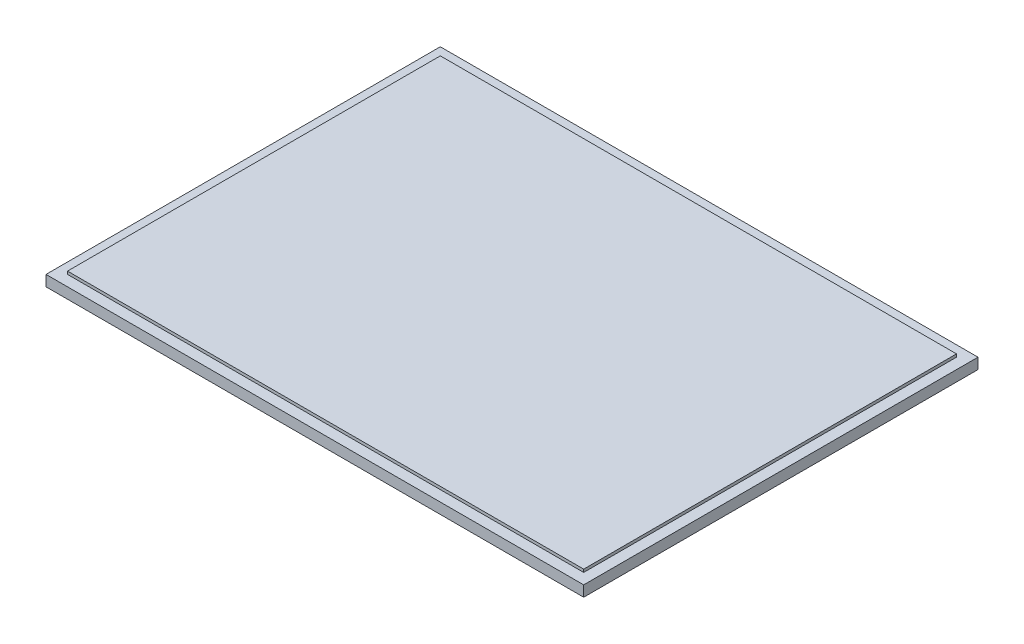
from build123d import *

# Parameters (mm, degrees)
SKETCH1_W           = 750
SKETCH1_H           = 550
BOSS_EXTRUDE1_DEPTH = 19
SKETCH3_W           = 750
SKETCH3_H           = 550
SKETCH3_W_2         = 720
SKETCH3_H_2         = 520
CUT_EXTRUDE2_DEPTH  = 4


with BuildPart() as part:
    # Sketch1 → Boss-Extrude1 (new body)
    with BuildSketch(Plane(origin=(0, 0, 0), x_dir=(1, 0, 0), z_dir=(0, 1, 0))):
        Rectangle(SKETCH1_W, SKETCH1_H)
    extrude(amount=BOSS_EXTRUDE1_DEPTH)

    # Sketch3 → Cut-Extrude2 (cut)
    with BuildSketch(Plane(origin=(0, 19, 0), x_dir=(1, 0, 0), z_dir=(0, 1, 0))):
        Rectangle(SKETCH3_W, SKETCH3_H)
        Rectangle(SKETCH3_W_2, SKETCH3_H_2, mode=Mode.SUBTRACT)
    extrude(amount=-CUT_EXTRUDE2_DEPTH, mode=Mode.SUBTRACT)


solid = part.part
